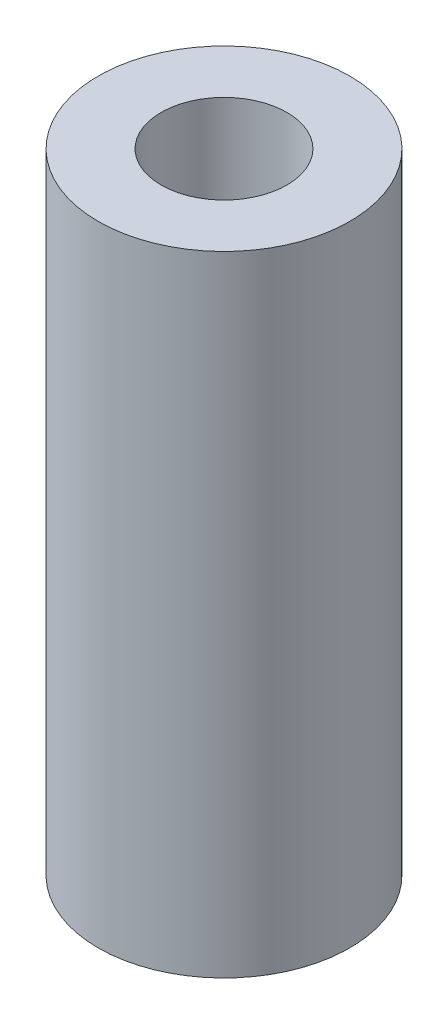
from build123d import *

# Parameters (mm, degrees)
SKETCH2_R           = 2
BOSS_EXTRUDE1_DEPTH = 10
SKETCH3_R           = 1
CUT_EXTRUDE1_DEPTH  = 10


with BuildPart() as part:
    # Sketch2 → Boss-Extrude1 (new body)
    with BuildSketch(Plane(origin=(0, 0, 0), x_dir=(1, 0, 0), z_dir=(0, 1, 0))):
        Circle(SKETCH2_R)
    extrude(amount=BOSS_EXTRUDE1_DEPTH)

    # Sketch3 → Cut-Extrude1 (cut)
    with BuildSketch(Plane(origin=(0, 10, 0), x_dir=(1, 0, 0), z_dir=(0, 1, 0))):
        Circle(SKETCH3_R)
    extrude(amount=-CUT_EXTRUDE1_DEPTH, mode=Mode.SUBTRACT)


solid = part.part
